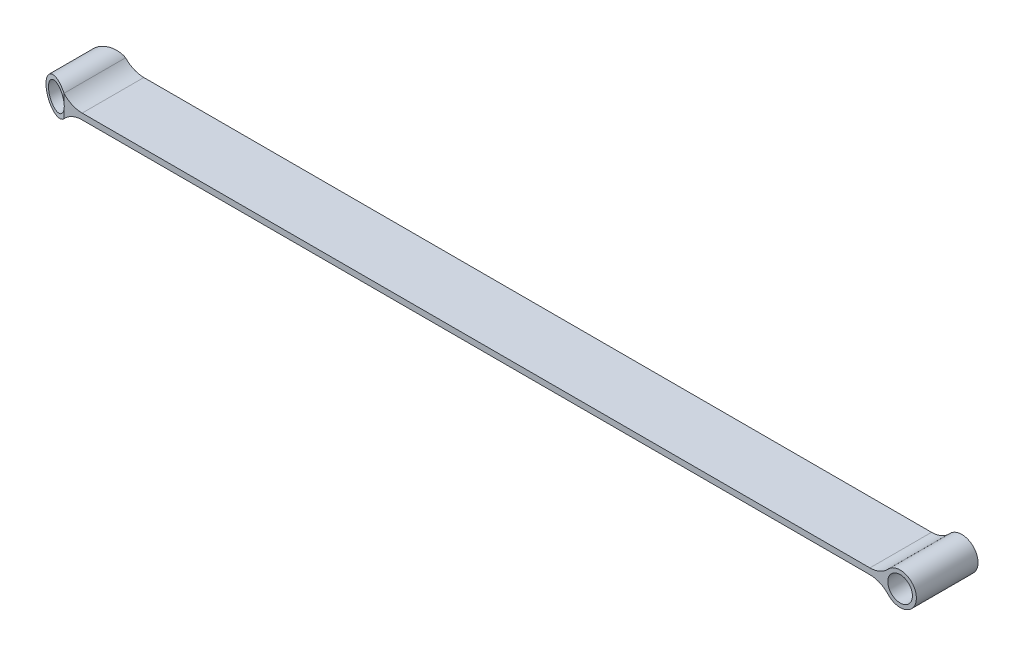
from build123d import *

# Parameters (mm, degrees)
SKETCH1_W               = 203.2
SKETCH1_H               = 15.875
BOSS_EXTRUDE1_DEPTH     = 1.524
SKETCH5_R               = 3.175
BOSS_EXTRUDE5_DEPTH     = 15.875
CUT_EXTRUDE1_DEPTH      = 4.429
CUT_EXTRUDE1_DEPTH_BACK = 5.953


with BuildPart() as part:
    # Sketch1 → Boss-Extrude1 (new body)
    with BuildSketch(Plane(origin=(0, 0, 0), x_dir=(1, 0, 0), z_dir=(0, 1, 0))):
        Rectangle(SKETCH1_W, SKETCH1_H)
    extrude(amount=BOSS_EXTRUDE1_DEPTH)

    # Sketch5 → Boss-Extrude5 (add, through all)
    with BuildSketch(Plane.XY.offset(7.9375)):
        with BuildLine():
            ThreePointArc((-106.126651501, -2.065662651), (-104.000712573, -0.539318363), (-101.439759837, 0))
            Line((-101.439759837, 0), (-101.6, 0))
            Line((-101.6, 0), (-101.6, 1.524))
            Line((-101.6, 1.524), (-101.439759837, 1.524))
            ThreePointArc((-101.439759837, 1.524), (-104.000712573, 2.063318363), (-106.126651501, 3.589662651))
            ThreePointArc((-106.126651501, 3.589662651), (-113.411, 0.762), (-106.126651501, -2.065662651))
        make_face()
        with Locations((-109.22, 0.762)):
            Circle(SKETCH5_R, mode=Mode.SUBTRACT)
    boss_extrude5 = extrude(amount=-BOSS_EXTRUDE5_DEPTH)

    # Mirror1: Boss-Extrude5 across plane
    add(boss_extrude5.mirror(Plane(origin=(0, 0, 0), x_dir=(0, 0, 1), z_dir=(1, 0, 0))))

    # Sketch6 → Cut-Extrude1 (cut, two sides)
    with BuildSketch(Plane.XZ) as cut_extrude1_sk:
        Polygon((-113.411, -5.28621397), (-106.126651501, -7.9375), (-113.411, -7.9375), align=None)
        Polygon((-113.411, 7.9375), (-113.411, 5.28621397), (-106.126651501, 7.9375), align=None)
    extrude(amount=CUT_EXTRUDE1_DEPTH, mode=Mode.SUBTRACT)
    extrude(cut_extrude1_sk.sketch, amount=-CUT_EXTRUDE1_DEPTH_BACK, mode=Mode.SUBTRACT)


solid = part.part
